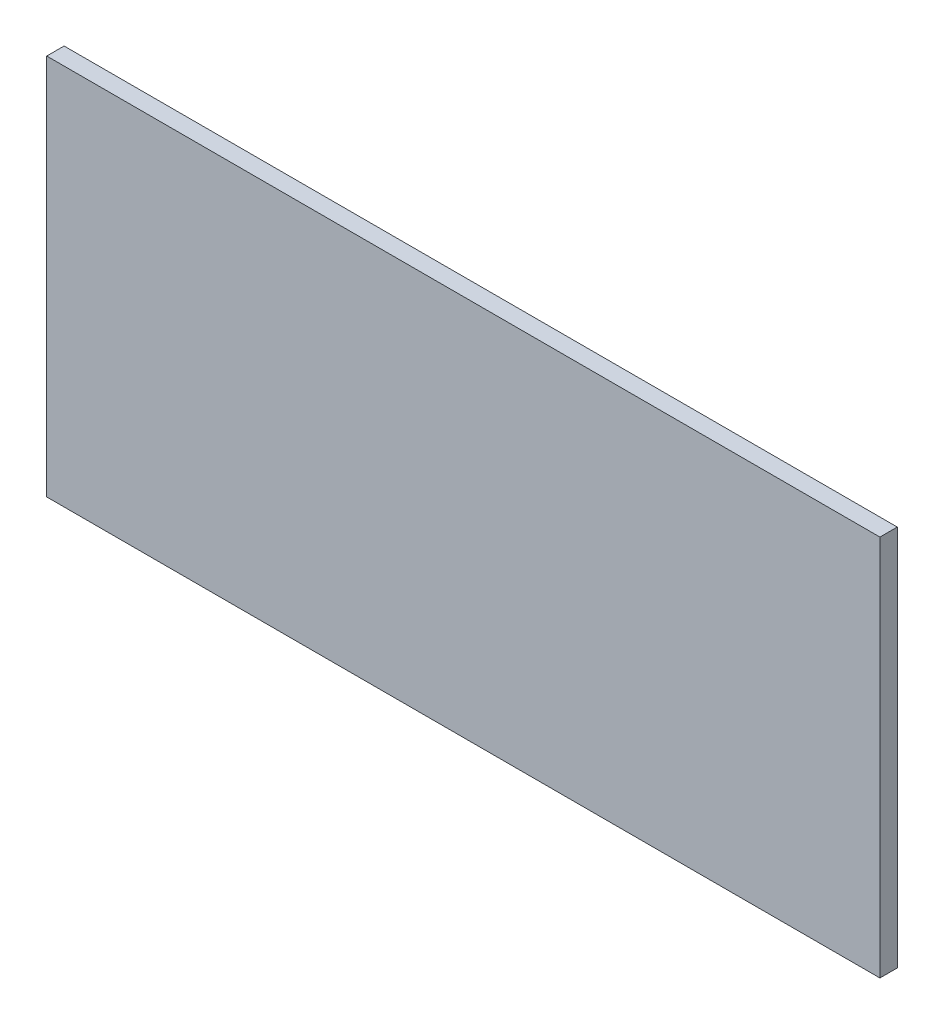
from build123d import *

# Parameters (mm, degrees)
SKETCH1_W           = 609.6
SKETCH1_H           = 279.4
BOSS_EXTRUDE1_DEPTH = 12.7


with BuildPart() as part:
    # Sketch1 → Boss-Extrude1 (new body)
    with BuildSketch(Plane.XY):
        with Locations((304.8, 139.7)):
            Rectangle(SKETCH1_W, SKETCH1_H)
    extrude(amount=BOSS_EXTRUDE1_DEPTH)


solid = part.part
